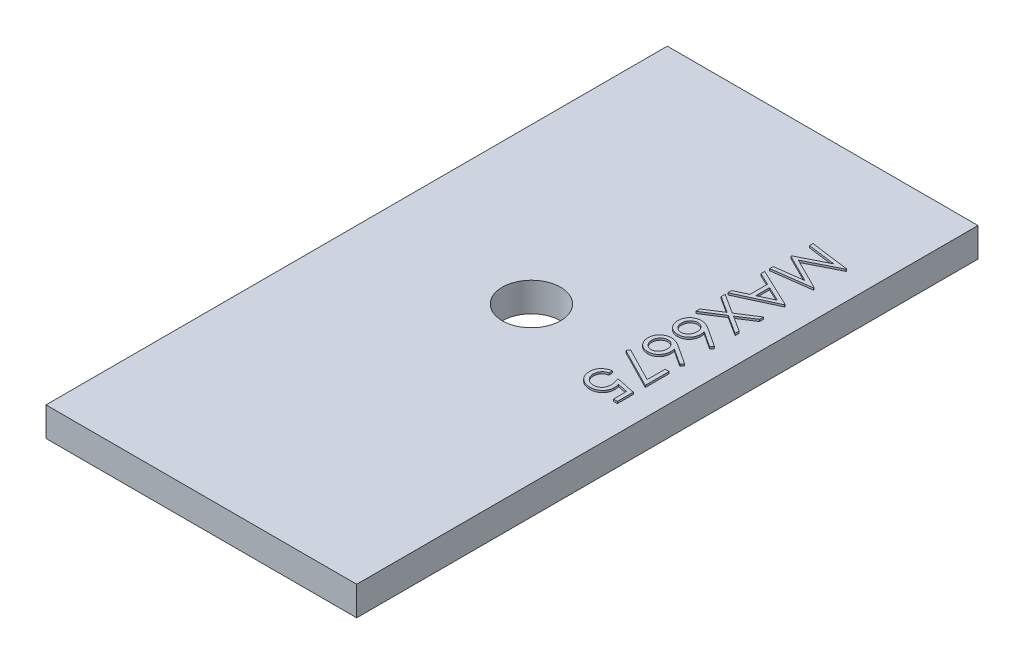
from build123d import *

# Parameters (mm, degrees)
SKETCH1_W           = 16
SKETCH1_H           = 32
BOSS_EXTRUDE1_DEPTH = 1.5
SKETCH2_R           = 1.5
CUT_EXTRUDE1_DEPTH  = 2.5
BOSS_EXTRUDE2_DEPTH = 0.1


with BuildPart() as part:
    # Sketch1 → Boss-Extrude1 (new body)
    with BuildSketch(Plane(origin=(0, 0, 0), x_dir=(1, 0, 0), z_dir=(0, 1, 0))):
        Rectangle(SKETCH1_W, SKETCH1_H)
    extrude(amount=BOSS_EXTRUDE1_DEPTH)

    # Sketch2 → Cut-Extrude1 (cut, through all)
    with BuildSketch(Plane(origin=(0, 1.5, 0), x_dir=(1, 0, 0), z_dir=(0, 1, 0))):
        with Locations((0, 1)):
            Circle(SKETCH2_R)
    extrude(amount=-CUT_EXTRUDE1_DEPTH, mode=Mode.SUBTRACT)

    # Sketch4 → Boss-Extrude2 (add)
    with BuildSketch(Plane(origin=(0, 1.5, 0), x_dir=(1, 0, 0), z_dir=(0, 1, 0))):
        Polygon((4.657935917, 10.846153846), (6.657935917, 10.58213141), (6.657935917, 10.556490385), (5.016910276, 9.730769231), (6.657935917, 8.907051282), (6.657935917, 8.881009615), (4.657935917, 8.615384615), (4.657935917, 8.795673077), (6.097038481, 8.987179487), (4.657935917, 9.709134615), (4.657935917, 9.749599359), (6.10024361, 10.474358974), (4.657935917, 10.665464744), align=None)
        Polygon((6.657935917, 7.384615385), (4.657935917, 6.461538462), (4.657935917, 6.656650641), (5.298961558, 6.952323718), (5.298961558, 7.858974359), (4.657935917, 8.163060897), (4.657935917, 8.358974359), (6.657935917, 7.41025641), align=None)
        Polygon((6.268112199, 7.399439103), (5.504089763, 7.76161859), (5.504089763, 7.046875), align=None, mode=Mode.SUBTRACT)
        Polygon((6.657935917, 6.294871795), (6.657935917, 6.087740385), (5.839826943, 5.564102564), (6.657935917, 5.040464744), (6.657935917, 4.833333333), (5.677967968, 5.460336538), (4.657935917, 4.807692308), (4.657935917, 5.014823718), (5.516108994, 5.564102564), (4.657935917, 6.11338141), (4.657935917, 6.320512821), (5.677967968, 5.667467949), align=None)
        with BuildLine():
            Line((6.709217968, 3.717948718), (6.600644251, 3.579727564))
            Line((6.600644251, 3.579727564), (5.792551302, 4.108173077))
            add(Edge.make_bspline(
                [(5.792551302, 4.108173077), (5.798159222, 4.072990062), (5.809098105, 4.004361612), (5.810902645, 3.934895384), (5.811782071, 3.901041667)],
                knots=[0, 0, 0, 0, 0.000106748, 0.000208224, 0.000208224, 0.000208224, 0.000208224], degree=3))
            add(Edge.make_bspline(
                [(5.811782071, 3.901041667), (5.811235722, 3.880714526), (5.810160249, 3.840701154), (5.801883763, 3.78195441), (5.788840842, 3.72550359), (5.769828124, 3.671582668), (5.745541064, 3.619998107), (5.716433138, 3.570453881), (5.681001321, 3.523881304), (5.641421346, 3.47968063), (5.597583069, 3.43955086), (5.55106802, 3.404021685), (5.501924659, 3.374177804), (5.450177879, 3.349964135), (5.395907445, 3.331161347), (5.339182794, 3.317454121), (5.27996481, 3.309351497), (5.239691567, 3.308251216), (5.219233994, 3.307692308)],
                knots=[0, 0, 0, 0, 6.0962e-05, 0.000120002, 0.000177629, 0.000234521, 0.000291158, 0.000348462, 0.000406555, 0.000466412, 0.000526241, 0.000584576, 0.000641742, 0.000698379, 0.00075565, 0.000813759, 0.000873196, 0.000934558, 0.000934558, 0.000934558, 0.000934558], degree=3))
            add(Edge.make_bspline(
                [(5.219233994, 3.307692308), (5.19126223, 3.308736038), (5.136252871, 3.310788642), (5.055797206, 3.325730727), (4.979764012, 3.351517428), (4.907854492, 3.386016941), (4.842160859, 3.430777346), (4.782791429, 3.483820887), (4.73104225, 3.545648974), (4.686648785, 3.614797504), (4.651378233, 3.689637687), (4.625301994, 3.768110068), (4.609720778, 3.849543906), (4.607680872, 3.904848687), (4.606653866, 3.932692308)],
                knots=[0, 0, 0, 0, 8.3896e-05, 0.00016499, 0.000244427, 0.000324163, 0.000403504, 0.000482092, 0.00056227, 0.000644621, 0.000727955, 0.0008098, 0.000892149, 0.000975645, 0.000975645, 0.000975645, 0.000975645], degree=3))
            add(Edge.make_bspline(
                [(4.606653866, 3.932692308), (4.607527124, 3.959604713), (4.609256896, 4.012913477), (4.624666035, 4.09133214), (4.649641401, 4.166682723), (4.684050019, 4.238435574), (4.727509957, 4.304908519), (4.779837562, 4.364359763), (4.839876333, 4.416582464), (4.907810447, 4.45981362), (4.980339969, 4.49504713), (5.056656781, 4.519897834), (5.135224976, 4.535968849), (5.188707268, 4.537626926), (5.215628225, 4.538461538)],
                knots=[0, 0, 0, 0, 8.0672e-05, 0.000159798, 0.000238728, 0.00031829, 0.000397853, 0.000476208, 0.000555168, 0.000635738, 0.000717092, 0.000796402, 0.000875997, 0.000956669, 0.000956669, 0.000956669, 0.000956669], degree=3))
            add(Edge.make_bspline(
                [(5.215628225, 4.538461538), (5.23621763, 4.537736711), (5.278238554, 4.53625741), (5.34206452, 4.527429113), (5.407116271, 4.511236937), (5.462262358, 4.493713464), (5.50793331, 4.476324888), (5.543998454, 4.460201801), (5.582084404, 4.442174225), (5.621470537, 4.421043396), (5.663282199, 4.398643011), (5.705970978, 4.37247682), (5.751095998, 4.345171998), (5.781139535, 4.325169181), (5.796557712, 4.314903846)],
                knots=[0, 0, 0, 0, 6.1782e-05, 0.000126091, 0.000192849, 0.000262663, 0.000299567, 0.000339392, 0.000381146, 0.000425948, 0.000473462, 0.000523414, 0.000576118, 0.000631678, 0.000631678, 0.000631678, 0.000631678], degree=3))
            Line((5.796557712, 4.314903846), (6.709217968, 3.717948718))
        make_face()
        with BuildLine():
            add(Edge.make_bspline(
                [(5.606653866, 3.938701923), (5.60620338, 3.953937014), (5.60531953, 3.983828136), (5.600327541, 4.02762741), (5.590869089, 4.068968655), (5.578634365, 4.108324055), (5.561975931, 4.145283422), (5.541981087, 4.180268353), (5.518208526, 4.212931697), (5.490923304, 4.242699829), (5.461486298, 4.270034325), (5.429767733, 4.293546456), (5.396736666, 4.313850137), (5.362082646, 4.330352672), (5.325827902, 4.343204509), (5.288136794, 4.352500553), (5.248757219, 4.357674152), (5.222052928, 4.358534852), (5.208416686, 4.358974359)],
                knots=[0, 0, 0, 0, 4.5717e-05, 8.9696e-05, 0.000131979, 0.000172777, 0.000213131, 0.000253333, 0.000293481, 0.000334041, 0.000374305, 0.000413808, 0.000452286, 0.000490457, 0.000528726, 0.000567497, 0.000606707, 0.000647621, 0.000647621, 0.000647621, 0.000647621], degree=3))
            add(Edge.make_bspline(
                [(5.208416686, 4.358974359), (5.194902927, 4.358615516), (5.168404455, 4.357911878), (5.129346155, 4.351552284), (5.091793741, 4.341768589), (5.055719748, 4.327447851), (5.021320954, 4.309485458), (4.988353014, 4.287380754), (4.956793173, 4.261508023), (4.927437257, 4.231431487), (4.900511298, 4.198996858), (4.876536374, 4.164695091), (4.856403848, 4.12863525), (4.8404875, 4.090611575), (4.827451631, 4.051156427), (4.818271832, 4.009968816), (4.81308345, 3.967012553), (4.812221558, 3.937914351), (4.811782071, 3.923076923)],
                knots=[0, 0, 0, 0, 4.0514e-05, 7.9443e-05, 0.000118412, 0.000156727, 0.000195614, 0.000234616, 0.000275603, 0.000317815, 0.000360495, 0.000401949, 0.000443197, 0.000484125, 0.000525428, 0.000567711, 0.000610497, 0.000655013, 0.000655013, 0.000655013, 0.000655013], degree=3))
            add(Edge.make_bspline(
                [(4.811782071, 3.923076923), (4.812221523, 3.908239471), (4.813083348, 3.879141221), (4.81827222, 3.836185303), (4.827450208, 3.794996415), (4.840492658, 3.75554591), (4.856384714, 3.717505098), (4.876662527, 3.681413692), (4.900365529, 3.646784433), (4.9274836, 3.614371083), (4.956627298, 3.584168835), (4.988638767, 3.558902101), (5.02105893, 3.536099058), (5.055856826, 3.518826551), (5.091772025, 3.504346324), (5.129351973, 3.494611992), (5.168402932, 3.488239238), (5.194902412, 3.487537408), (5.208416686, 3.487179487)],
                knots=[0, 0, 0, 0, 4.4516e-05, 8.7302e-05, 0.000129585, 0.000170888, 0.000211816, 0.000253064, 0.000294848, 0.000337527, 0.00037974, 0.000420473, 0.000459699, 0.000498402, 0.000536717, 0.000575687, 0.000614615, 0.000655129, 0.000655129, 0.000655129, 0.000655129], degree=3))
            add(Edge.make_bspline(
                [(5.208416686, 3.487179487), (5.2220723, 3.487490275), (5.248873829, 3.488100251), (5.288101314, 3.495133018), (5.326134393, 3.50463194), (5.362116308, 3.519983068), (5.397042105, 3.538267515), (5.429913579, 3.5615607), (5.461661983, 3.588266906), (5.491118535, 3.619195284), (5.518061894, 3.65284259), (5.541843924, 3.688624048), (5.561915491, 3.726056881), (5.578662366, 3.765104927), (5.590747791, 3.806215124), (5.600263927, 3.848723895), (5.605327937, 3.893174889), (5.60620626, 3.923332951), (5.606653866, 3.938701923)],
                knots=[0, 0, 0, 0, 4.0914e-05, 8.0302e-05, 0.000119271, 0.000158257, 0.000197331, 0.000237341, 0.000278842, 0.000321628, 0.000365239, 0.00040802, 0.000450323, 0.000492514, 0.000535225, 0.000578681, 0.000623058, 0.000669176, 0.000669176, 0.000669176, 0.000669176], degree=3))
        make_face(mode=Mode.SUBTRACT)
        with BuildLine():
            Line((6.709217968, 2.179487179), (6.600644251, 2.041266026))
            Line((6.600644251, 2.041266026), (5.792551302, 2.569711538))
            add(Edge.make_bspline(
                [(5.792551302, 2.569711538), (5.798159222, 2.534528523), (5.809098105, 2.465900073), (5.810902645, 2.396433846), (5.811782071, 2.362580128)],
                knots=[0, 0, 0, 0, 0.000106748, 0.000208224, 0.000208224, 0.000208224, 0.000208224], degree=3))
            add(Edge.make_bspline(
                [(5.811782071, 2.362580128), (5.811235722, 2.342252987), (5.810160249, 2.302239616), (5.801883763, 2.243492872), (5.788840842, 2.187042051), (5.769828124, 2.13312113), (5.745541064, 2.081536569), (5.716433138, 2.031992342), (5.681001321, 1.985419765), (5.641421346, 1.941219091), (5.597583069, 1.901089321), (5.55106802, 1.865560147), (5.501924659, 1.835716266), (5.450177879, 1.811502596), (5.395907445, 1.792699809), (5.339182794, 1.778992583), (5.27996481, 1.770889958), (5.239691567, 1.769789678), (5.219233994, 1.769230769)],
                knots=[0, 0, 0, 0, 6.0962e-05, 0.000120002, 0.000177629, 0.000234521, 0.000291158, 0.000348462, 0.000406555, 0.000466412, 0.000526241, 0.000584576, 0.000641742, 0.000698379, 0.00075565, 0.000813759, 0.000873196, 0.000934558, 0.000934558, 0.000934558, 0.000934558], degree=3))
            add(Edge.make_bspline(
                [(5.219233994, 1.769230769), (5.19126223, 1.7702745), (5.136252871, 1.772327104), (5.055797206, 1.787269189), (4.979764012, 1.813055889), (4.907854492, 1.847555402), (4.842160859, 1.892315808), (4.782791429, 1.945359349), (4.73104225, 2.007187435), (4.686648785, 2.076335965), (4.651378233, 2.151176149), (4.625301994, 2.22964853), (4.609720778, 2.311082368), (4.607680872, 2.366387148), (4.606653866, 2.394230769)],
                knots=[0, 0, 0, 0, 8.3896e-05, 0.00016499, 0.000244427, 0.000324163, 0.000403504, 0.000482092, 0.00056227, 0.000644621, 0.000727955, 0.0008098, 0.000892149, 0.000975645, 0.000975645, 0.000975645, 0.000975645], degree=3))
            add(Edge.make_bspline(
                [(4.606653866, 2.394230769), (4.607527124, 2.421143175), (4.609256896, 2.474451938), (4.624666035, 2.552870602), (4.649641401, 2.628221185), (4.684050019, 2.699974035), (4.727509957, 2.76644698), (4.779837562, 2.825898225), (4.839876333, 2.878120925), (4.907810447, 2.921352082), (4.980339969, 2.956585592), (5.056656781, 2.981436296), (5.135224976, 2.997507311), (5.188707268, 2.999165387), (5.215628225, 3)],
                knots=[0, 0, 0, 0, 8.0672e-05, 0.000159798, 0.000238728, 0.00031829, 0.000397853, 0.000476208, 0.000555168, 0.000635738, 0.000717092, 0.000796402, 0.000875997, 0.000956669, 0.000956669, 0.000956669, 0.000956669], degree=3))
            add(Edge.make_bspline(
                [(5.215628225, 3), (5.23621763, 2.999275172), (5.278238554, 2.997795872), (5.34206452, 2.988967574), (5.407116271, 2.972775398), (5.462262358, 2.955251925), (5.50793331, 2.93786335), (5.543998454, 2.921740263), (5.582084404, 2.903712687), (5.621470537, 2.882581857), (5.663282199, 2.860181473), (5.705970978, 2.834015282), (5.751095998, 2.806710459), (5.781139535, 2.786707642), (5.796557712, 2.776442308)],
                knots=[0, 0, 0, 0, 6.1782e-05, 0.000126091, 0.000192849, 0.000262663, 0.000299567, 0.000339392, 0.000381146, 0.000425948, 0.000473462, 0.000523414, 0.000576118, 0.000631678, 0.000631678, 0.000631678, 0.000631678], degree=3))
            Line((5.796557712, 2.776442308), (6.709217968, 2.179487179))
        make_face()
        with BuildLine():
            add(Edge.make_bspline(
                [(5.606653866, 2.400240385), (5.60620338, 2.415475475), (5.60531953, 2.445366597), (5.600327541, 2.489165872), (5.590869089, 2.530507117), (5.578634365, 2.569862516), (5.561975931, 2.606821883), (5.541981087, 2.641806815), (5.518208526, 2.674470159), (5.490923304, 2.70423829), (5.461486298, 2.731572787), (5.429767733, 2.755084918), (5.396736666, 2.775388599), (5.362082646, 2.791891133), (5.325827902, 2.804742971), (5.288136794, 2.814039015), (5.248757219, 2.819212614), (5.222052928, 2.820073314), (5.208416686, 2.820512821)],
                knots=[0, 0, 0, 0, 4.5717e-05, 8.9696e-05, 0.000131979, 0.000172777, 0.000213131, 0.000253333, 0.000293481, 0.000334041, 0.000374305, 0.000413808, 0.000452286, 0.000490457, 0.000528726, 0.000567497, 0.000606707, 0.000647621, 0.000647621, 0.000647621, 0.000647621], degree=3))
            add(Edge.make_bspline(
                [(5.208416686, 2.820512821), (5.194902927, 2.820153977), (5.168404455, 2.81945034), (5.129346155, 2.813090746), (5.091793741, 2.80330705), (5.055719748, 2.788986312), (5.021320954, 2.77102392), (4.988353014, 2.748919215), (4.956793173, 2.723046484), (4.927437257, 2.692969948), (4.900511298, 2.66053532), (4.876536374, 2.626233552), (4.856403848, 2.590173711), (4.8404875, 2.552150036), (4.827451631, 2.512694889), (4.818271832, 2.471507278), (4.81308345, 2.428551015), (4.812221558, 2.399452812), (4.811782071, 2.384615385)],
                knots=[0, 0, 0, 0, 4.0514e-05, 7.9443e-05, 0.000118412, 0.000156727, 0.000195614, 0.000234616, 0.000275603, 0.000317815, 0.000360495, 0.000401949, 0.000443197, 0.000484125, 0.000525428, 0.000567711, 0.000610497, 0.000655013, 0.000655013, 0.000655013, 0.000655013], degree=3))
            add(Edge.make_bspline(
                [(4.811782071, 2.384615385), (4.812221523, 2.369777933), (4.813083348, 2.340679682), (4.81827222, 2.297723765), (4.827450208, 2.256534877), (4.840492658, 2.217084372), (4.856384714, 2.179043559), (4.876662527, 2.142952153), (4.900365529, 2.108322895), (4.9274836, 2.075909545), (4.956627298, 2.045707297), (4.988638767, 2.020440562), (5.02105893, 1.99763752), (5.055856826, 1.980365012), (5.091772025, 1.965884786), (5.129351973, 1.956150453), (5.168402932, 1.949777699), (5.194902412, 1.94907587), (5.208416686, 1.948717949)],
                knots=[0, 0, 0, 0, 4.4516e-05, 8.7302e-05, 0.000129585, 0.000170888, 0.000211816, 0.000253064, 0.000294848, 0.000337527, 0.00037974, 0.000420473, 0.000459699, 0.000498402, 0.000536717, 0.000575687, 0.000614615, 0.000655129, 0.000655129, 0.000655129, 0.000655129], degree=3))
            add(Edge.make_bspline(
                [(5.208416686, 1.948717949), (5.2220723, 1.949028737), (5.248873829, 1.949638713), (5.288101314, 1.956671479), (5.326134393, 1.966170401), (5.362116308, 1.98152153), (5.397042105, 1.999805977), (5.429913579, 2.023099161), (5.461661983, 2.049805367), (5.491118535, 2.080733745), (5.518061894, 2.114381052), (5.541843924, 2.15016251), (5.561915491, 2.187595342), (5.578662366, 2.226643388), (5.590747791, 2.267753585), (5.600263927, 2.310262356), (5.605327937, 2.354713351), (5.60620626, 2.384871413), (5.606653866, 2.400240385)],
                knots=[0, 0, 0, 0, 4.0914e-05, 8.0302e-05, 0.000119271, 0.000158257, 0.000197331, 0.000237341, 0.000278842, 0.000321628, 0.000365239, 0.00040802, 0.000450323, 0.000492514, 0.000535225, 0.000578681, 0.000623058, 0.000669176, 0.000669176, 0.000669176, 0.000669176], degree=3))
        make_face(mode=Mode.SUBTRACT)
        Polygon((6.657935917, 1.435897436), (6.657935917, 0.205128205), (4.606653866, 1.256410256), (4.691990404, 1.411458333), (6.452807712, 0.508814103), (6.452807712, 1.435897436), align=None)
        with BuildLine():
            Line((6.657935917, -1.230769231), (6.452807712, -1.230769231))
            Line((6.452807712, -1.230769231), (6.452807712, -0.550480769))
            Line((6.452807712, -0.550480769), (5.926766045, -0.442708333))
            add(Edge.make_bspline(
                [(5.926766045, -0.442708333), (5.932611915, -0.463883119), (5.943937363, -0.504905916), (5.956512089, -0.565454408), (5.964092343, -0.622935667), (5.965127377, -0.660235879), (5.965628225, -0.678285256)],
                knots=[0, 0, 0, 0, 6.5887e-05, 0.000127645, 0.000185389, 0.000239529, 0.000239529, 0.000239529, 0.000239529], degree=3))
            add(Edge.make_bspline(
                [(5.965628225, -0.678285256), (5.965144707, -0.700618745), (5.964193989, -0.744531963), (5.955069016, -0.808783885), (5.940696821, -0.87011299), (5.920651649, -0.928414494), (5.89485378, -0.983813972), (5.863045547, -1.036002049), (5.825446965, -1.085274492), (5.782420796, -1.130979941), (5.735008817, -1.172379611), (5.684197987, -1.208923229), (5.629942087, -1.239315726), (5.572481034, -1.264320089), (5.51191124, -1.284158636), (5.44778437, -1.297398971), (5.38066949, -1.306205581), (5.334781396, -1.30719021), (5.31138143, -1.307692308)],
                knots=[0, 0, 0, 0, 6.6966e-05, 0.000131671, 0.000194254, 0.000255703, 0.000316285, 0.000377231, 0.000438691, 0.000501898, 0.000565215, 0.000627251, 0.00068932, 0.000751397, 0.000814999, 0.000880141, 0.000947575, 0.001017744, 0.001017744, 0.001017744, 0.001017744], degree=3))
            add(Edge.make_bspline(
                [(5.31138143, -1.307692308), (5.295082997, -1.307312316), (5.26270639, -1.306557467), (5.214624303, -1.302717524), (5.167558661, -1.295328478), (5.121510169, -1.285393762), (5.076540389, -1.272550336), (5.03266568, -1.256833591), (4.989750943, -1.238307424), (4.947793367, -1.217390941), (4.908086438, -1.193194448), (4.87001722, -1.167706266), (4.83498674, -1.139472376), (4.801716153, -1.109859723), (4.771512045, -1.077684219), (4.743081853, -1.043944539), (4.717660526, -1.007848898), (4.694278644, -0.970043542), (4.673343415, -0.930552311), (4.655879695, -0.888974771), (4.640572593, -0.846223658), (4.628124777, -0.801917936), (4.618467071, -0.756143439), (4.611890304, -0.708742539), (4.607105134, -0.659953085), (4.606805314, -0.626881717), (4.606653866, -0.610176282)],
                knots=[0, 0, 0, 0, 4.8904e-05, 9.7148e-05, 0.000144575, 0.000191724, 0.000238392, 0.000284773, 0.000331435, 0.000378558, 0.00042528, 0.00047084, 0.000515891, 0.000560143, 0.000604352, 0.000648159, 0.000692404, 0.000736656, 0.000781458, 0.000826332, 0.000871824, 0.000917611, 0.000964285, 0.001012049, 0.001061125, 0.00111122, 0.00111122, 0.00111122, 0.00111122], degree=3))
            add(Edge.make_bspline(
                [(4.606653866, -0.610176282), (4.607048665, -0.590248203), (4.607825386, -0.551042062), (4.615949741, -0.49360139), (4.627588065, -0.438337171), (4.645087946, -0.385686772), (4.667047748, -0.335205981), (4.694625422, -0.287566794), (4.726313425, -0.24183284), (4.763205098, -0.199247114), (4.803906217, -0.15980262), (4.847601331, -0.123951002), (4.894464179, -0.092509347), (4.944095802, -0.065349345), (4.996581599, -0.042215719), (5.052078626, -0.024033491), (5.110307701, -0.009360758), (5.150395352, -0.003153004), (5.17075643, 0)],
                knots=[0, 0, 0, 0, 5.9744e-05, 0.000117539, 0.000173727, 0.000228967, 0.00028368, 0.000338591, 0.00039383, 0.000450366, 0.000507315, 0.000563693, 0.000619697, 0.000676356, 0.000733226, 0.000791505, 0.000851362, 0.000913144, 0.000913144, 0.000913144, 0.000913144], degree=3))
            Line((5.17075643, 0), (5.17075643, -0.179487179))
            add(Edge.make_bspline(
                [(5.17075643, -0.179487179), (5.151682352, -0.183900719), (5.115020914, -0.192383786), (5.063541507, -0.21105263), (5.017493684, -0.233738017), (4.976833974, -0.261327074), (4.941191408, -0.293571985), (4.90915456, -0.3301027), (4.880634995, -0.371439646), (4.856709523, -0.417356471), (4.836334716, -0.465827168), (4.822760366, -0.516549669), (4.813217509, -0.568152576), (4.812262148, -0.603054445), (4.811782071, -0.620592949)],
                knots=[0, 0, 0, 0, 5.8691e-05, 0.000112807, 0.000163871, 0.000212321, 0.0002597, 0.000307678, 0.000357798, 0.000409952, 0.000462776, 0.000515168, 0.000567202, 0.000619761, 0.000619761, 0.000619761, 0.000619761], degree=3))
            add(Edge.make_bspline(
                [(4.811782071, -0.620592949), (4.812251087, -0.63771206), (4.813174583, -0.67141973), (4.82028259, -0.721026236), (4.831229774, -0.768919307), (4.847612548, -0.814626368), (4.867523816, -0.858947248), (4.893075288, -0.900760831), (4.922481012, -0.941276761), (4.956170515, -0.979235694), (4.993296055, -1.014001094), (5.032997423, -1.044718877), (5.075349907, -1.070305685), (5.11962028, -1.091868033), (5.166293741, -1.108241347), (5.215151555, -1.119921907), (5.266314401, -1.126780798), (5.301211149, -1.12772433), (5.31899361, -1.128205128)],
                knots=[0, 0, 0, 0, 5.1338e-05, 0.000101086, 0.000150064, 0.000198467, 0.000246512, 0.000295571, 0.000345174, 0.000396545, 0.000447567, 0.00049757, 0.000546836, 0.000595755, 0.000645047, 0.000694897, 0.000746233, 0.000799572, 0.000799572, 0.000799572, 0.000799572], degree=3))
            add(Edge.make_bspline(
                [(5.31899361, -1.128205128), (5.335046563, -1.12788946), (5.366485943, -1.127271229), (5.412279753, -1.120401173), (5.455923921, -1.110777291), (5.497028151, -1.096001047), (5.536194354, -1.077743744), (5.572584233, -1.054580839), (5.607132704, -1.028103252), (5.638436251, -0.997090674), (5.667522971, -0.963272776), (5.692282255, -0.92586453), (5.713121144, -0.885719189), (5.731102205, -0.843301395), (5.744017099, -0.797607413), (5.753712982, -0.749540696), (5.759321775, -0.698582597), (5.760099995, -0.663742201), (5.76050002, -0.645833333)],
                knots=[0, 0, 0, 0, 4.8119e-05, 9.4239e-05, 0.000138653, 0.000181989, 0.000224999, 0.000268019, 0.000311134, 0.000355332, 0.000399962, 0.000444742, 0.000489544, 0.000535526, 0.000582689, 0.000631718, 0.000682509, 0.000736233, 0.000736233, 0.000736233, 0.000736233], degree=3))
            add(Edge.make_bspline(
                [(5.76050002, -0.645833333), (5.760179519, -0.630196463), (5.759523405, -0.598185362), (5.754359923, -0.548968349), (5.746416403, -0.497473721), (5.734967256, -0.443501558), (5.720632135, -0.387199978), (5.702729366, -0.328475351), (5.682107635, -0.267326258), (5.666112717, -0.226168539), (5.657935917, -0.205128205)],
                knots=[0, 0, 0, 0, 4.6902e-05, 9.6016e-05, 0.000148317, 0.000203162, 0.000261465, 0.000322557, 0.000387298, 0.00045501, 0.00045501, 0.00045501, 0.00045501], degree=3))
            Line((5.657935917, -0.205128205), (6.657935917, -0.41025641))
            Line((6.657935917, -0.41025641), (6.657935917, -1.230769231))
        make_face()
    extrude(amount=BOSS_EXTRUDE2_DEPTH)


solid = part.part
